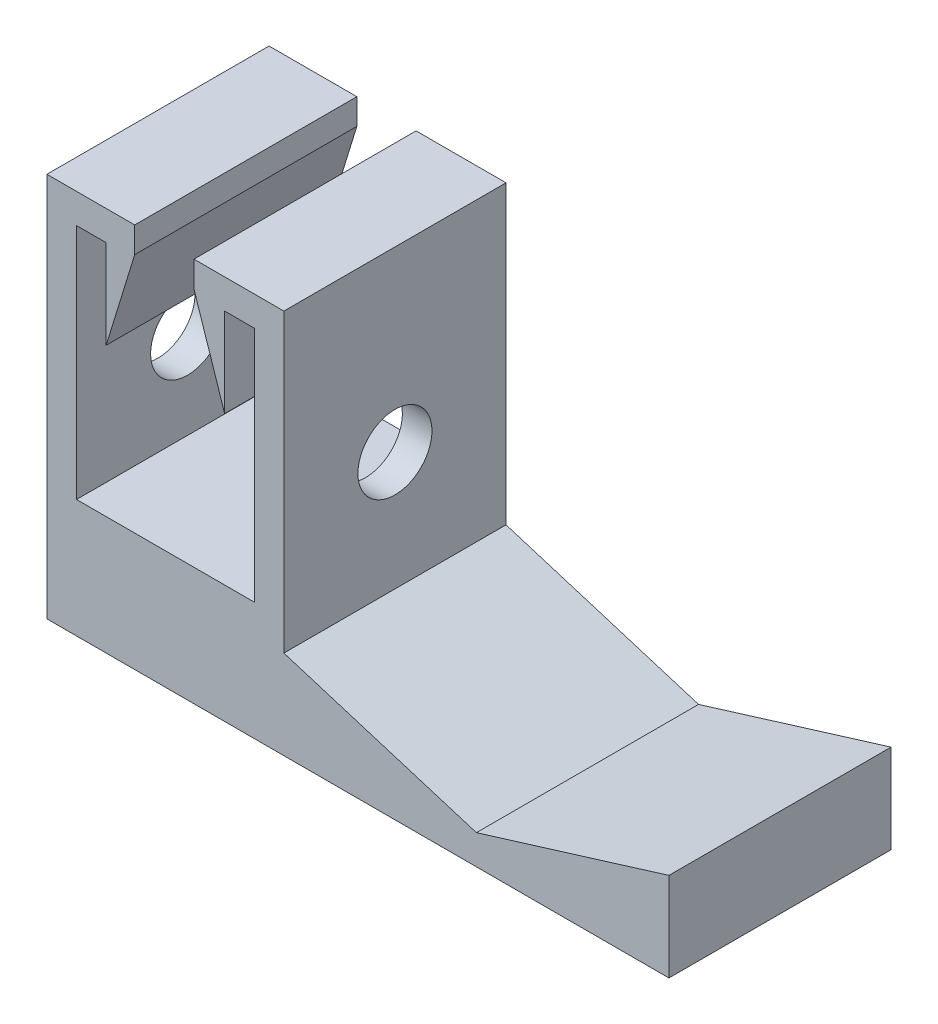
from build123d import *

# Parameters (mm, degrees)
BOSS_EXTRUDE1_DEPTH = 37.5
SKETCH2_R           = 12.5
CUT_EXTRUDE1_DEPTH  = 100


with BuildPart() as part:
    # Sketch1 → Boss-Extrude1 (new body, symmetric)
    with BuildSketch(Plane.XY):
        Polygon((-95, 39.909181495), (-35, 39.909181495), (-35, 120), (-45, 120), (-45, 90), (-55.365508708, 121.312096701), (-55.365508708, 130), (-25, 130), (-25, 30), (40, 10), (105, 30), (105, 0), (-105, 0), (-105, 130), (-75.365508708, 130), (-75.365508708, 121.312096701), (-85, 90), (-85, 120), (-95, 120), align=None)
    extrude(amount=BOSS_EXTRUDE1_DEPTH, both=True)

    # Sketch2 → Cut-Extrude1 (cut)
    with BuildSketch(Plane.ZY.offset(105)):
        with Locations((0, 70)):
            Circle(SKETCH2_R)
    extrude(amount=-CUT_EXTRUDE1_DEPTH, mode=Mode.SUBTRACT)


solid = part.part
